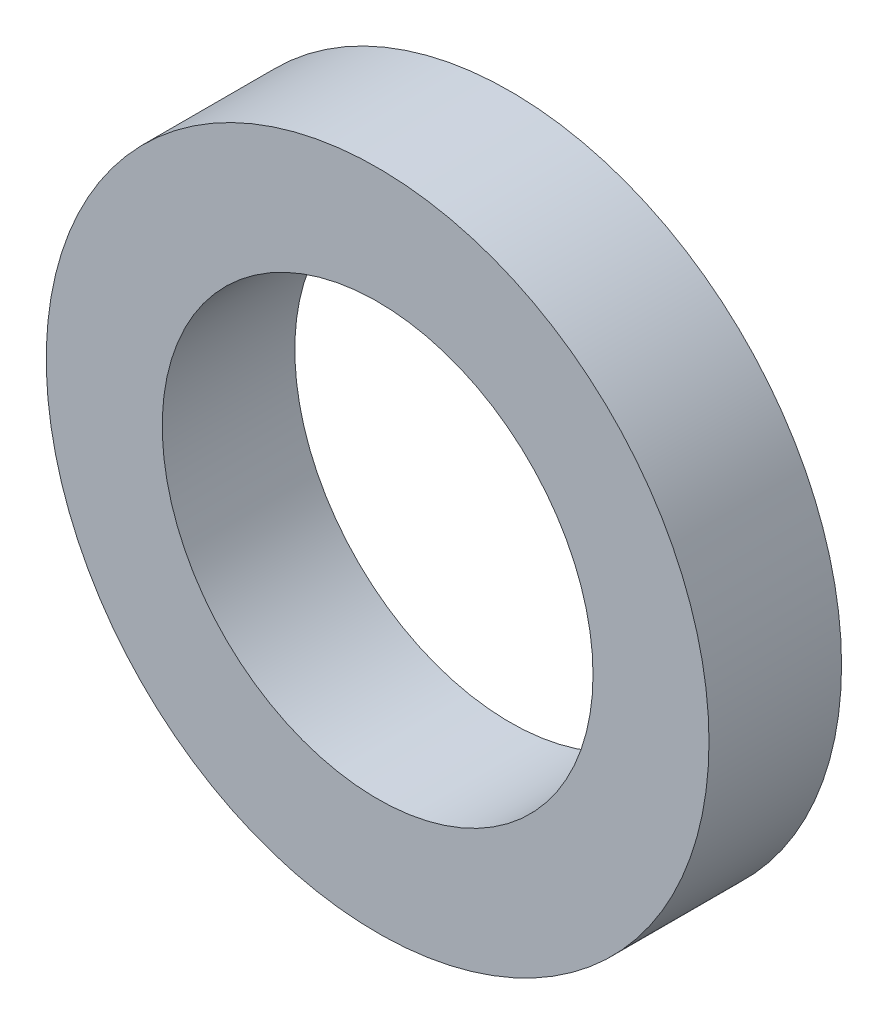
from build123d import *

# Parameters (mm, degrees)
SKETCH_1_R      = 5
SKETCH_1_R_2    = 3.25
EXTRUDE_1_DEPTH = 2


with BuildPart() as part:
    # ｽｹｯﾁ1 → ﾎﾞｽ - 押し出し1 (new body)
    with BuildSketch(Plane.XY):
        Circle(SKETCH_1_R)
        Circle(SKETCH_1_R_2, mode=Mode.SUBTRACT)
    extrude(amount=EXTRUDE_1_DEPTH)


solid = part.part
